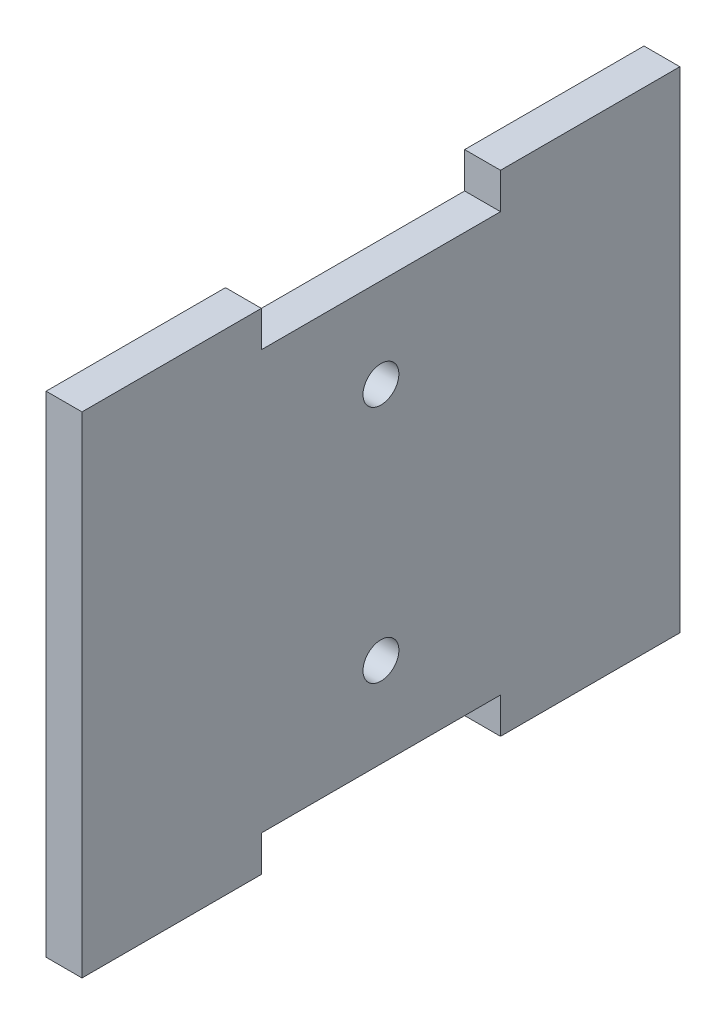
from build123d import *

# Parameters (mm, degrees)
SKETCH_1_R      = 1.5
EXTRUDE_1_DEPTH = 3


with BuildPart() as part:
    # 草图1 → 凸台-拉伸1 (new body)
    with BuildSketch(Plane(origin=(0, 0, 0), x_dir=(0, 0, -1), z_dir=(1, 0, 0))):
        Polygon((-10, 17.5), (10, 17.5), (10, 20.5), (25, 20.5), (25, -20.5), (10, -20.5), (10, -17.5), (-10, -17.5), (-10, -20.5), (-25, -20.5), (-25, 20.5), (-10, 20.5), align=None)
        with Locations((0, -10)):
            Circle(SKETCH_1_R, mode=Mode.SUBTRACT)
        with Locations((0, 10)):
            Circle(SKETCH_1_R, mode=Mode.SUBTRACT)
    extrude(amount=EXTRUDE_1_DEPTH)


solid = part.part
